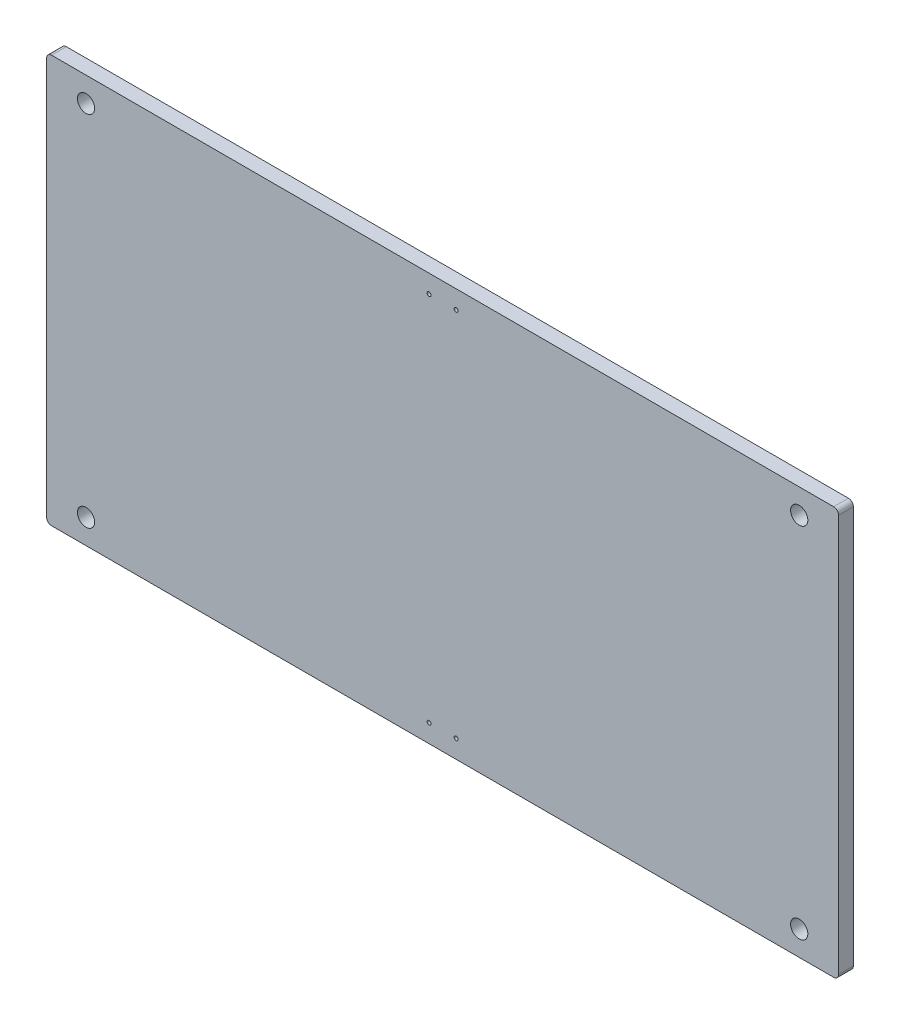
from build123d import *

# Parameters (mm, degrees)
SKETCH1_W           = 321.81
SKETCH1_H           = 165.61
BOSS_EXTRUDE1_DEPTH = 6
SKETCH3_R           = 3.5
CUT_EXTRUDE1_DEPTH  = 7
SKETCH6_R           = 0.8
CUT_EXTRUDE5_DEPTH  = 10
FILLET1_R           = 2


with BuildPart() as part:
    # Sketch1 → Boss-Extrude1 (new body)
    with BuildSketch(Plane.XY):
        with Locations((591.992540984, 348.670409836)):
            Rectangle(SKETCH1_W, SKETCH1_H)
    extrude(amount=BOSS_EXTRUDE1_DEPTH)

    # Sketch3 → Cut-Extrude1 (cut, through all)
    with BuildSketch(Plane.XY.offset(6)):
        with Locations((447.087540984, 421.475409836)):
            Circle(SKETCH3_R)
        with Locations((736.897540984, 421.475409836)):
            Circle(SKETCH3_R)
        with Locations((736.897540984, 275.865409836)):
            Circle(SKETCH3_R)
        with Locations((447.087540984, 275.865409836)):
            Circle(SKETCH3_R)
    extrude(amount=-CUT_EXTRUDE1_DEPTH, mode=Mode.SUBTRACT)

    # Sketch6 → Cut-Extrude5 (cut)
    with BuildSketch(Plane.XY.offset(6)):
        with Locations((586.492540984, 424.075409836)):
            Circle(SKETCH6_R)
        with Locations((597.492540984, 424.075409836)):
            Circle(SKETCH6_R)
        with Locations((586.492540984, 273.265409836)):
            Circle(SKETCH6_R)
        with Locations((597.492540984, 273.265409836)):
            Circle(SKETCH6_R)
    extrude(amount=-CUT_EXTRUDE5_DEPTH, mode=Mode.SUBTRACT)

    # Fillet1
    fillet1_edges = [part.edges().sort_by_distance(p)[0] for p in [
        (431.087540984, 431.475409836, 3),
        (752.897540984, 431.475409836, 3),
        (752.897540984, 265.865409836, 3),
        (431.087540984, 265.865409836, 3),
    ]]
    fillet(fillet1_edges, radius=FILLET1_R)


solid = part.part
